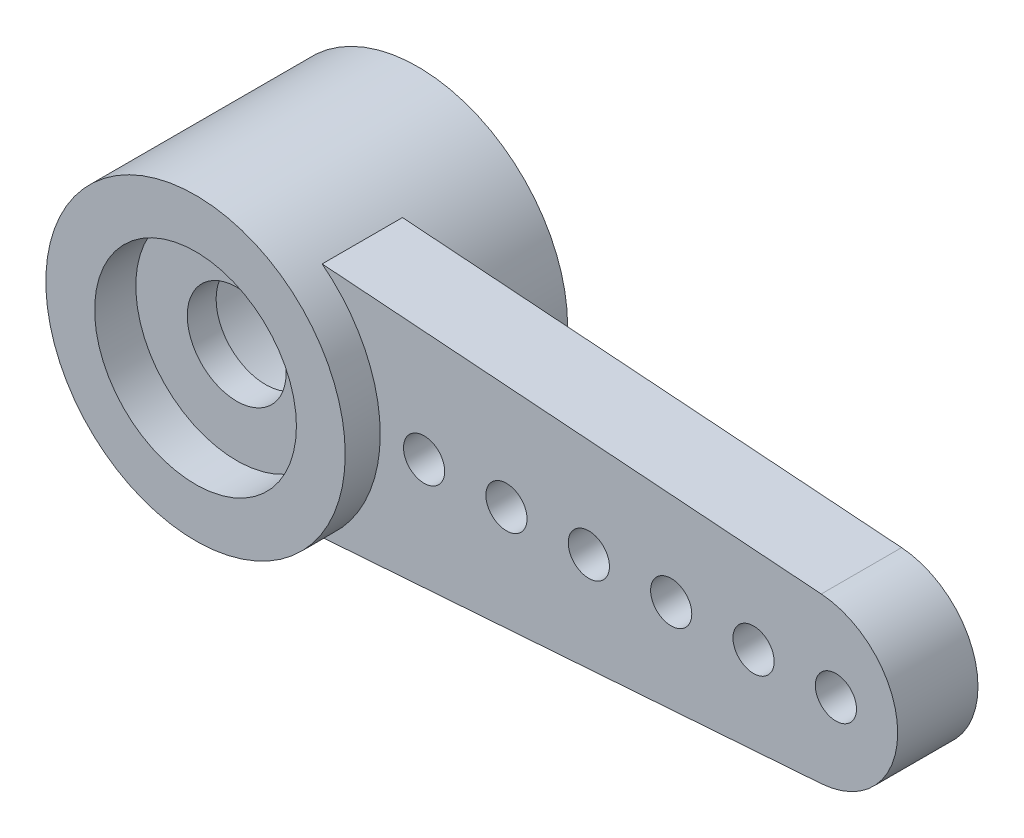
from build123d import *

# Parameters (mm, degrees)
ESQUISSE1_R             = 3.635
ESQUISSE1_R_2           = 1.2
BOSS_EXTRU_1_DEPTH      = 5.4
BOSS_EXTRU_2_DEPTH      = 1.95
ESQUISSE3_R             = 2.45
ENL_V_MAT_EXTRU_1_DEPTH = 1
ESQUISSE4_R             = 2.45
ENL_V_MAT_EXTRU_2_DEPTH = 3.7
ESQUISSE5_R             = 0.5
ENL_V_MAT_EXTRU_3_DEPTH = 3.7


with BuildPart() as part:
    # Esquisse1 → Boss.-Extru.1 (new body)
    with BuildSketch(Plane.XY):
        Circle(ESQUISSE1_R)
        Circle(ESQUISSE1_R_2, mode=Mode.SUBTRACT)
    extrude(amount=BOSS_EXTRU_1_DEPTH)

    # Esquisse2 → Boss.-Extru.2 (add)
    with BuildSketch(Plane.XY.offset(4.55)):
        with BuildLine():
            Line((2.224320121, 2.875), (14.344868259, 1.994746397))
            ThreePointArc((14.344868259, 1.994746397), (16.2, 0), (14.344868259, -1.994746397))
            Line((14.344868259, -1.994746397), (2.224320121, -2.875))
            ThreePointArc((2.224320121, -2.875), (3.635, 0), (2.224320121, 2.875))
        make_face()
    extrude(amount=-BOSS_EXTRU_2_DEPTH)

    # Esquisse3 → Enlèv. mat.-Extru.1 (cut)
    with BuildSketch(Plane.XY.offset(5.4)):
        Circle(ESQUISSE3_R)
    extrude(amount=-ENL_V_MAT_EXTRU_1_DEPTH, mode=Mode.SUBTRACT)

    # Esquisse4 → Enlèv. mat.-Extru.2 (cut)
    with BuildSketch(Plane(origin=(0, 0, 0), x_dir=(-1, 0, 0), z_dir=(0, 0, -1))):
        Circle(ESQUISSE4_R)
    extrude(amount=-ENL_V_MAT_EXTRU_2_DEPTH, mode=Mode.SUBTRACT)

    # Esquisse5 → Enlèv. mat.-Extru.3 (cut)
    with BuildSketch(Plane.XY.offset(4.55)):
        with Locations((14.7, 0)):
            Circle(ESQUISSE5_R)
        with Locations((12.7, 0)):
            Circle(ESQUISSE5_R)
        with Locations((10.7, 0)):
            Circle(ESQUISSE5_R)
        with Locations((8.7, 0)):
            Circle(ESQUISSE5_R)
        with Locations((6.7, 0)):
            Circle(ESQUISSE5_R)
        with Locations((4.7, 0)):
            Circle(ESQUISSE5_R)
    extrude(amount=-ENL_V_MAT_EXTRU_3_DEPTH, mode=Mode.SUBTRACT)


solid = part.part
